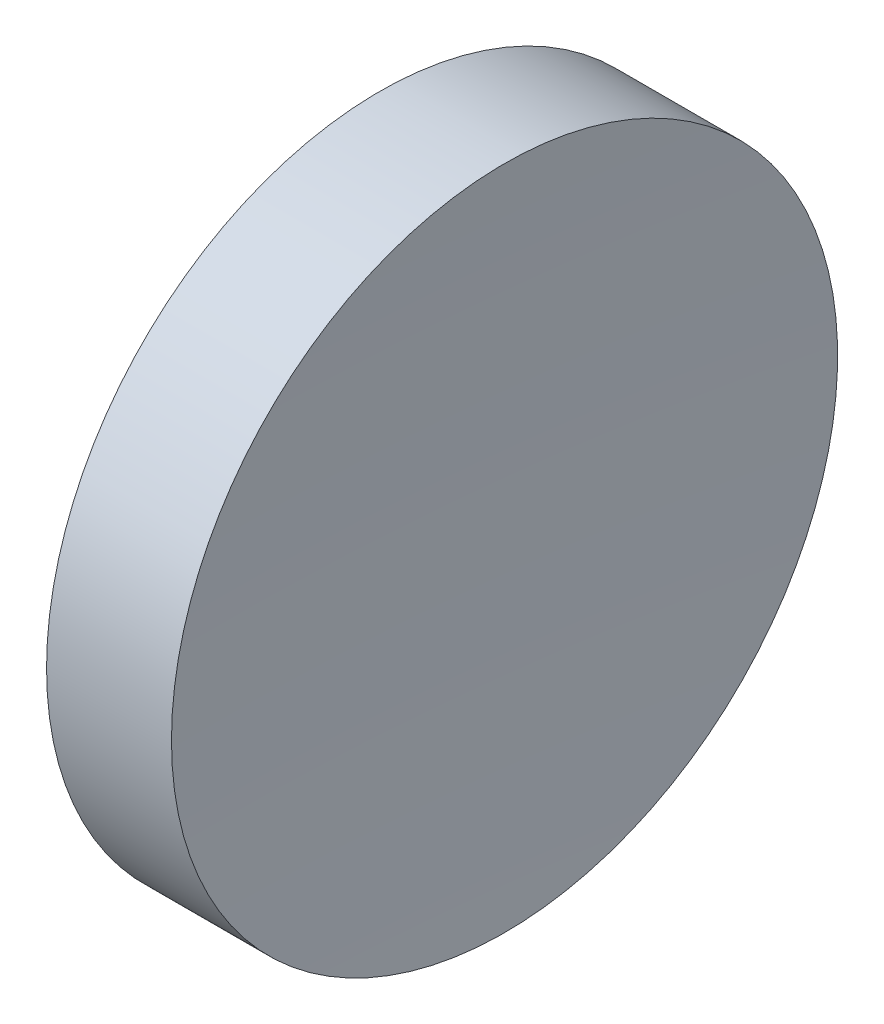
from build123d import *


with BuildPart() as part:
    # 草图1 → 旋转1 (revolve)
    with BuildSketch(Plane(origin=(0, 0, 0), x_dir=(1, 0, 0), z_dir=(0, 1, 0)), mode=Mode.PRIVATE) as revolve_1_sk:
        with BuildLine():
            Line((0, 0), (8.88, 0))
            ThreePointArc((8.88, 0), (9.041420249, 12.704101398), (9.525576769, 25.4))
            Line((9.525576769, 25.4), (0, 25.4))
            Line((0, 25.4), (0, 0))
        make_face()
    revolve(revolve_1_sk.sketch.rotate(Axis((0, 0, 0), (1, 0, 0)), 180), axis=Axis((0, 0, 0), (1, 0, 0)))  # turned: the seam where the file's is


solid = part.part
